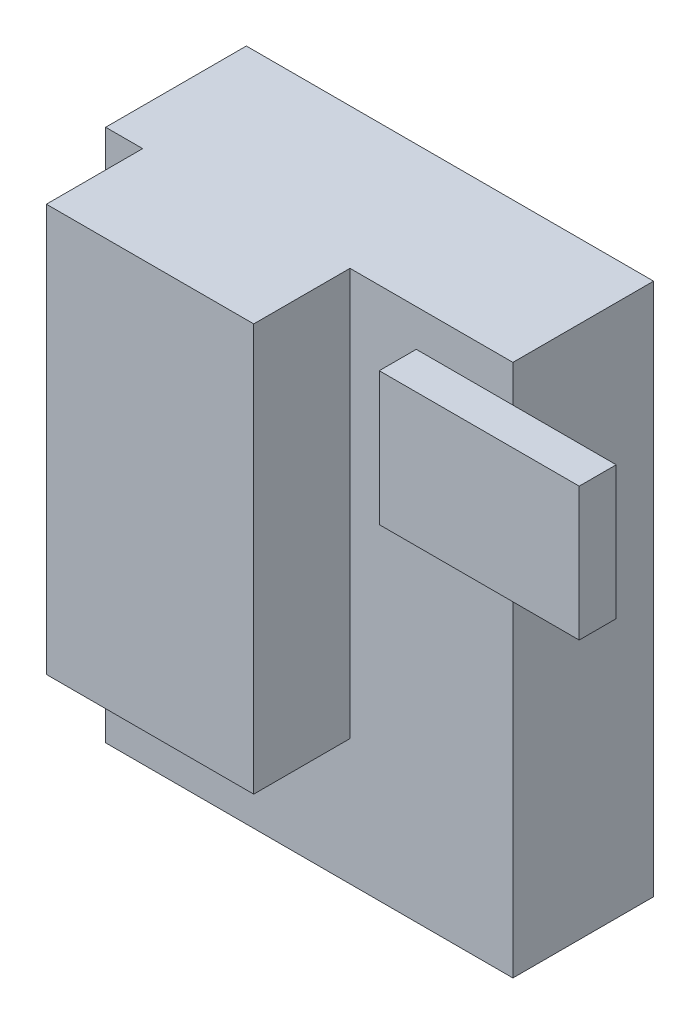
from build123d import *

# Parameters (mm, degrees)
SKIZZE1_W                       = 55
SKIZZE1_H                       = 72
AUFSATZ_LINEAR_AUSTRAGEN1_DEPTH = 19
SKIZZE2_W                       = 28
SKIZZE2_H                       = 55
AUFSATZ_LINEAR_AUSTRAGEN2_DEPTH = 13
SKIZZE3_W                       = 27
SKIZZE3_H                       = 18
AUFSATZ_LINEAR_AUSTRAGEN3_DEPTH = 5


with BuildPart() as part:
    # Skizze1 → Aufsatz-Linear austragen1 (new body)
    with BuildSketch(Plane.XY):
        with Locations((0.254783725, -15.710963455)):
            Rectangle(SKIZZE1_W, SKIZZE1_H)
    extrude(amount=AUFSATZ_LINEAR_AUSTRAGEN1_DEPTH)

    # Skizze2 → Aufsatz-Linear austragen2 (add)
    with BuildSketch(Plane.XY.offset(19)):
        with Locations((-8.245216275, -7.210963455)):
            Rectangle(SKIZZE2_W, SKIZZE2_H)
    extrude(amount=AUFSATZ_LINEAR_AUSTRAGEN2_DEPTH)

    # Skizze3 → Aufsatz-Linear austragen3 (add)
    with BuildSketch(Plane.XY.offset(19)):
        with Locations((28.20593288, 6.289036545)):
            Rectangle(SKIZZE3_W, SKIZZE3_H)
    extrude(amount=AUFSATZ_LINEAR_AUSTRAGEN3_DEPTH)


solid = part.part
